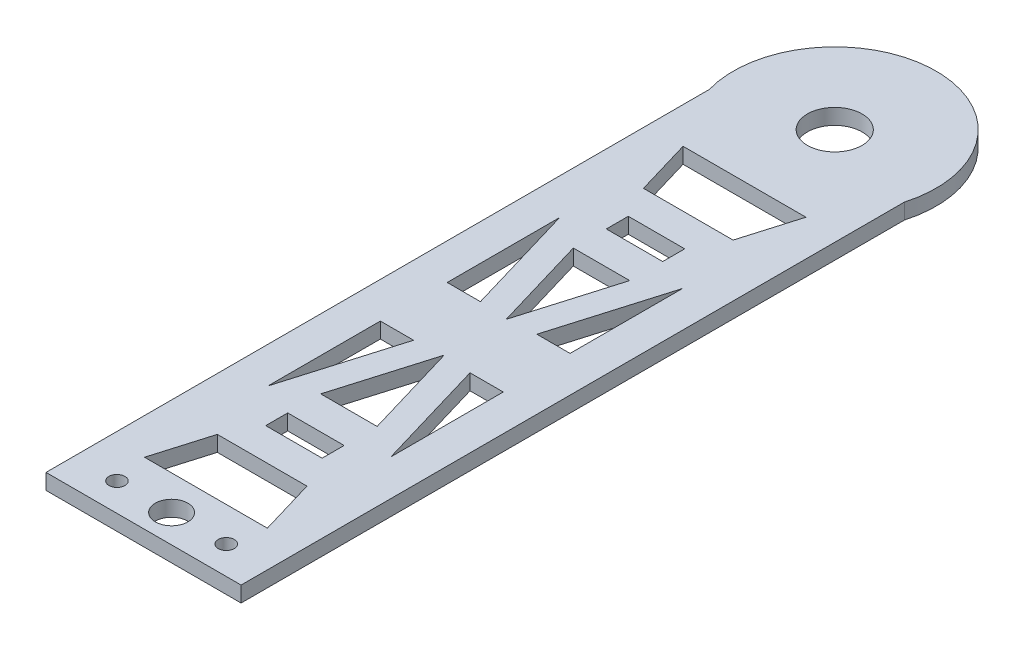
from build123d import *

# Parameters (mm, degrees)
BOSS_EXTRUDE1_DEPTH     = 2
SKETCH5_W               = 3.614771896
SKETCH5_H               = 2.818898279
CUT_EXTRUDE4_DEPTH      = 2
MIRROR3_COPY_1_SKETCH_W = 3.614771896
MIRROR3_COPY_1_SKETCH_H = 2.818898279
MIRROR3_COPY_1_DEPTH    = 2
SKETCH6_R               = 3.5
CUT_EXTRUDE5_DEPTH      = 3
CUT_EXTRUDE5_DEPTH_BACK = 1
CUT_EXTRUDE7_REACH      = 4
SKETCH8_R               = 2.084098117
SKETCH8_R_2             = 1.022428323


with BuildPart() as part:
    # Sketch2 → Boss-Extrude1 (new body)
    with BuildSketch(Plane(origin=(0, 0, 0), x_dir=(1, 0, 0), z_dir=(0, 1, 0))):
        with BuildLine():
            Line((-12.5, -42.5), (12.5, -42.5))
            Line((12.5, -42.5), (12.5, 42.5))
            ThreePointArc((12.5, 42.5), (0, 59.070714214), (-12.5, 42.5))
            Line((-12.5, 42.5), (-12.5, -42.5))
        make_face()
    extrude(amount=BOSS_EXTRUDE1_DEPTH)

    # Sketch5 → Cut-Extrude4 (cut)
    with BuildSketch(Plane(origin=(0, 0, 0), x_dir=(1, 0, 0), z_dir=(0, 1, 0))):
        Polygon((0, 34.507006909), (7.873050165, 34.507006909), (5.742382303, 27.303155751), (0, 27.303155751), align=None)
        with Locations((1.807385948, 21.821964654)):
            Rectangle(SKETCH5_W, SKETCH5_H)
        Polygon((0, 16.184168096), (3.614771896, 16.184168096), (0, 3.962517237), align=None)
        Polygon((7.873050165, 18.689855455), (3.614771896, 4.28215314), (7.873050165, 4.28215314), align=None)
    cut_extrude4 = extrude(amount=CUT_EXTRUDE4_DEPTH, mode=Mode.SUBTRACT)

    # Mirror1: Cut-Extrude4 across plane
    add(cut_extrude4.mirror(Plane(origin=(0, 0, 0), x_dir=(0, 0, 1), z_dir=(1, 0, 0))), mode=Mode.SUBTRACT)

    # Mirror3: Cut-Extrude4 across plane
    add(cut_extrude4.mirror(Plane.XY), mode=Mode.SUBTRACT)

    # Mirror3 copy 1 sketch → Mirror3 copy 1 (cut)
    with BuildSketch(Plane(origin=(0, 0, 0), x_dir=(-1, 0, 0), z_dir=(0, 1, 0))):
        Polygon((0, 34.507006909), (7.873050165, 34.507006909), (5.742382303, 27.303155751), (0, 27.303155751), align=None)
        with Locations((1.807385948, 21.821964654)):
            Rectangle(MIRROR3_COPY_1_SKETCH_W, MIRROR3_COPY_1_SKETCH_H)
        Polygon((0, 16.184168096), (3.614771896, 16.184168096), (0, 3.962517237), align=None)
        Polygon((7.873050165, 18.689855455), (3.614771896, 4.28215314), (7.873050165, 4.28215314), align=None)
    extrude(amount=MIRROR3_COPY_1_DEPTH, mode=Mode.SUBTRACT)

    # Sketch6 → Cut-Extrude5 (cut, two sides)
    with BuildSketch(Plane(origin=(0, 0, 0), x_dir=(1, 0, 0), z_dir=(0, 1, 0))) as cut_extrude5_sk:
        with Locations((0, 46.070714214)):
            Circle(SKETCH6_R)
    extrude(amount=CUT_EXTRUDE5_DEPTH, mode=Mode.SUBTRACT)
    extrude(cut_extrude5_sk.sketch, amount=-CUT_EXTRUDE5_DEPTH_BACK, mode=Mode.SUBTRACT)

    # Sketch8 → Cut-Extrude7 (cut, up to next)
    with BuildSketch(Plane(origin=(0, 0, 0), x_dir=(1, 0, 0), z_dir=(0, 1, 0)), mode=Mode.PRIVATE) as cut_extrude7_sk1:
        with Locations((0, -38.904058143)):
            Circle(SKETCH8_R)
    cut_extrude7_tool1 = extrude(cut_extrude7_sk1.sketch, amount=CUT_EXTRUDE7_REACH, mode=Mode.PRIVATE) & part.part
    add(cut_extrude7_tool1.solids().sort_by_distance((0, 0, 38.904058))[0], mode=Mode.SUBTRACT)
    # Sketch8 → Cut-Extrude7 (cut, up to next)
    with BuildSketch(Plane(origin=(0, 0, 0), x_dir=(1, 0, 0), z_dir=(0, 1, 0)), mode=Mode.PRIVATE) as cut_extrude7_sk2:
        with Locations((7, -38.904058143)):
            Circle(SKETCH8_R_2)
    cut_extrude7_tool2 = extrude(cut_extrude7_sk2.sketch, amount=CUT_EXTRUDE7_REACH, mode=Mode.PRIVATE) & part.part
    add(cut_extrude7_tool2.solids().sort_by_distance((7, 0, 38.904058))[0], mode=Mode.SUBTRACT)
    # Sketch8 → Cut-Extrude7 (cut, up to next)
    with BuildSketch(Plane(origin=(0, 0, 0), x_dir=(1, 0, 0), z_dir=(0, 1, 0)), mode=Mode.PRIVATE) as cut_extrude7_sk3:
        with Locations((-7, -38.904058143)):
            Circle(SKETCH8_R_2)
    cut_extrude7_tool3 = extrude(cut_extrude7_sk3.sketch, amount=CUT_EXTRUDE7_REACH, mode=Mode.PRIVATE) & part.part
    add(cut_extrude7_tool3.solids().sort_by_distance((-7, 0, 38.904058))[0], mode=Mode.SUBTRACT)


solid = part.part
